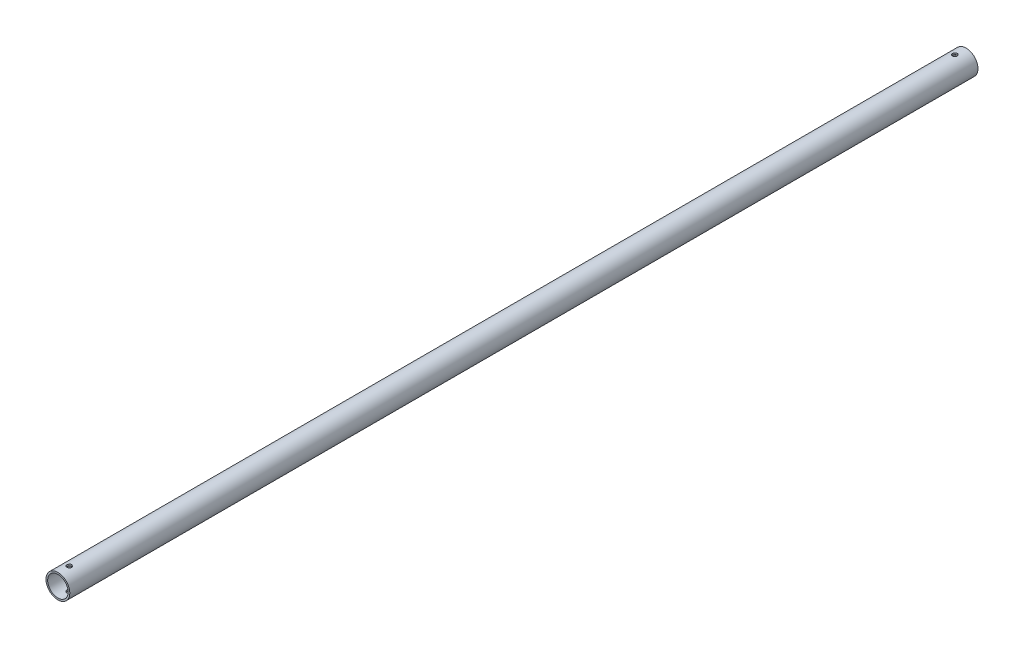
from build123d import *

# Parameters (mm, degrees)
SKETCH1_R           = 6.35
SKETCH1_R_2         = 5.461
BOSS_EXTRUDE1_DEPTH = 242
SKETCH2_R           = 1.25
CUT_EXTRUDE1_DEPTH  = 7.35


with BuildPart() as part:
    # Sketch1 → Boss-Extrude1 (new body, symmetric)
    with BuildSketch(Plane.XY):
        Circle(SKETCH1_R)
        Circle(SKETCH1_R_2, mode=Mode.SUBTRACT)
    extrude(amount=BOSS_EXTRUDE1_DEPTH, both=True)

    # Sketch2 → Cut-Extrude1 (cut, symmetric)
    with BuildSketch(Plane(origin=(0, 0, 0), x_dir=(1, 0, 0), z_dir=(0, 1, 0))):
        with Locations((0, 236)):
            Circle(SKETCH2_R)
    cut_extrude1 = extrude(amount=CUT_EXTRUDE1_DEPTH, both=True, mode=Mode.SUBTRACT)

    # Mirror1: Cut-Extrude1 across plane
    add(cut_extrude1.mirror(Plane.XY), mode=Mode.SUBTRACT)


solid = part.part
